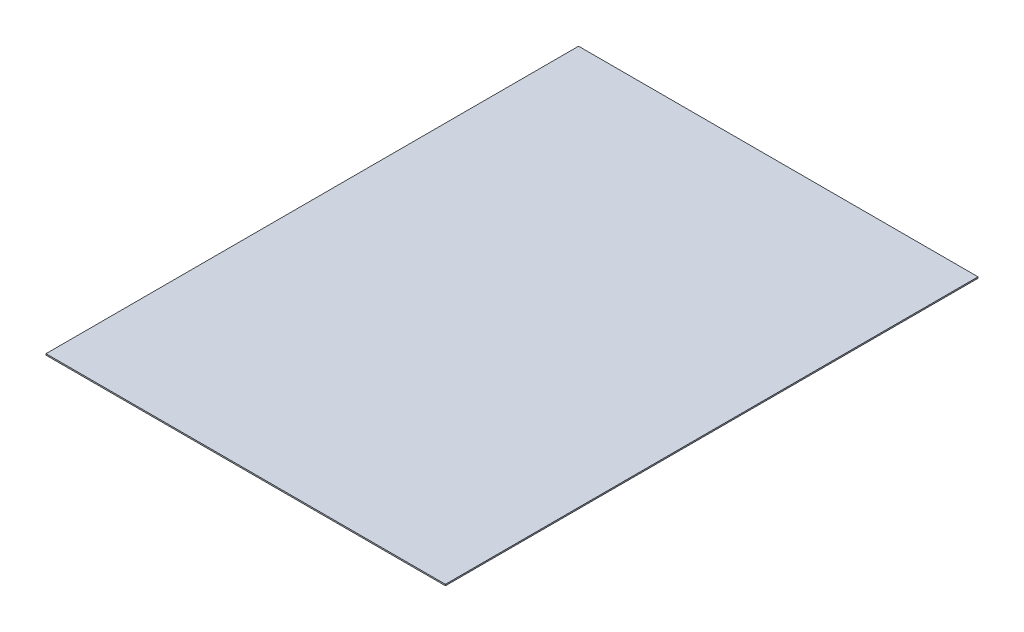
from build123d import *

# Parameters (mm, degrees)
SKETCH_1_W      = 3000
SKETCH_1_H      = 4000
EXTRUDE_1_DEPTH = 10


with BuildPart() as part:
    # 草图1 → 凸台-拉伸1 (new body)
    with BuildSketch(Plane(origin=(0, 0, 0), x_dir=(1, 0, 0), z_dir=(0, 1, 0))):
        Rectangle(SKETCH_1_W, SKETCH_1_H)
    extrude(amount=EXTRUDE_1_DEPTH)


solid = part.part
